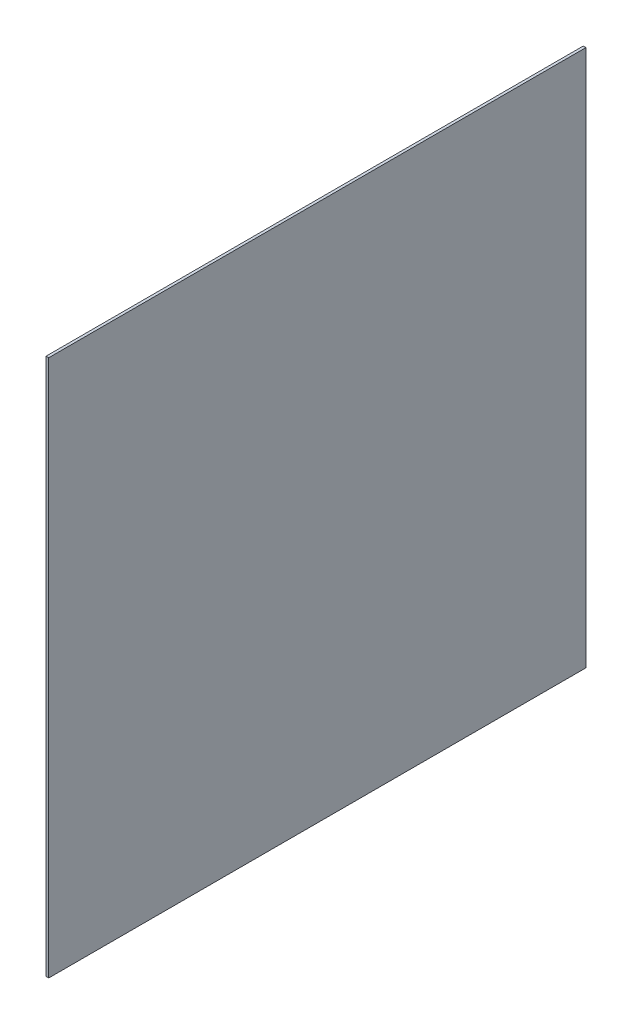
from build123d import *

# Parameters (mm, degrees)
SKETCH_1_W      = 200
SKETCH_1_H      = 200
EXTRUDE_1_DEPTH = 1


with BuildPart() as part:
    # 草图1 → 凸台-拉伸1 (new body)
    with BuildSketch(Plane(origin=(0, 0, 0), x_dir=(0, 0, -1), z_dir=(1, 0, 0))):
        Rectangle(SKETCH_1_W, SKETCH_1_H)
    extrude(amount=EXTRUDE_1_DEPTH)


solid = part.part
